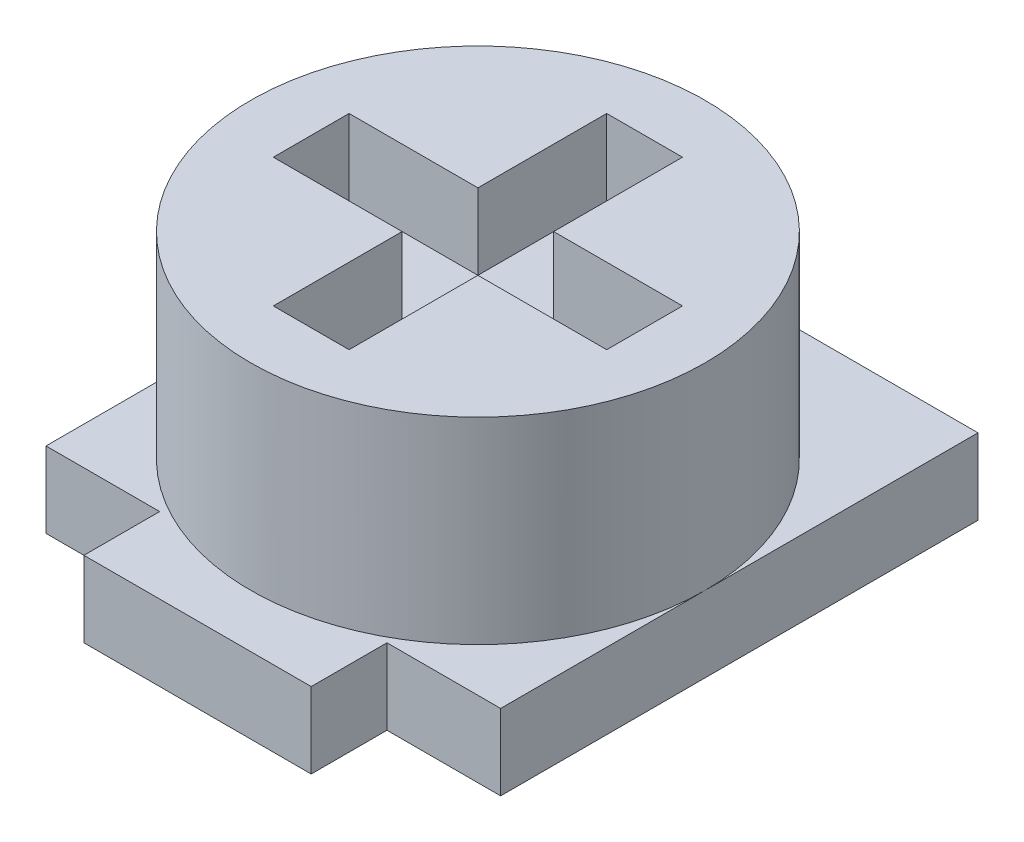
from build123d import *

# Parameters (mm, degrees)
SKETCH1_R           = 1.5
BOSS_EXTRUDE1_DEPTH = 1.8
BOSS_EXTRUDE2_DEPTH = 0.5
SKETCH4_W           = 0.85
SKETCH4_H           = 0.5
SKETCH4_W_2         = 0.5
SKETCH4_H_2         = 0.85
CUT_EXTRUDE1_DEPTH  = 0.5


with BuildPart() as part:
    # Sketch1 → Boss-Extrude1 (new body)
    with BuildSketch(Plane(origin=(0, 0, 0), x_dir=(1, 0, 0), z_dir=(0, 1, 0))):
        Circle(SKETCH1_R)
    extrude(amount=BOSS_EXTRUDE1_DEPTH)

    # Sketch2 → Boss-Extrude2 (add)
    with BuildSketch(Plane.XZ):
        Polygon((1.5, 1.35), (1.5, -1.8), (-1.5, -1.8), (-1.5, 1.35), (-0.75, 1.35), (-0.75, 1.85), (0.75, 1.85), (0.75, 1.35), align=None)
    extrude(amount=-BOSS_EXTRUDE2_DEPTH)

    # Sketch4 → Cut-Extrude1 (cut)
    with BuildSketch(Plane(origin=(0, 1.8, 0), x_dir=(1, 0, 0), z_dir=(0, 1, 0))):
        with Locations((0.675, 0)):
            Rectangle(SKETCH4_W, SKETCH4_H)
        Rectangle(SKETCH4_W_2, SKETCH4_H)
        with Locations((0, -0.675)):
            Rectangle(SKETCH4_W_2, SKETCH4_H_2)
        with Locations((-0.675, 0)):
            Rectangle(SKETCH4_W, SKETCH4_H)
        with Locations((0, 0.675)):
            Rectangle(SKETCH4_W_2, SKETCH4_H_2)
    extrude(amount=-CUT_EXTRUDE1_DEPTH, mode=Mode.SUBTRACT)


solid = part.part
